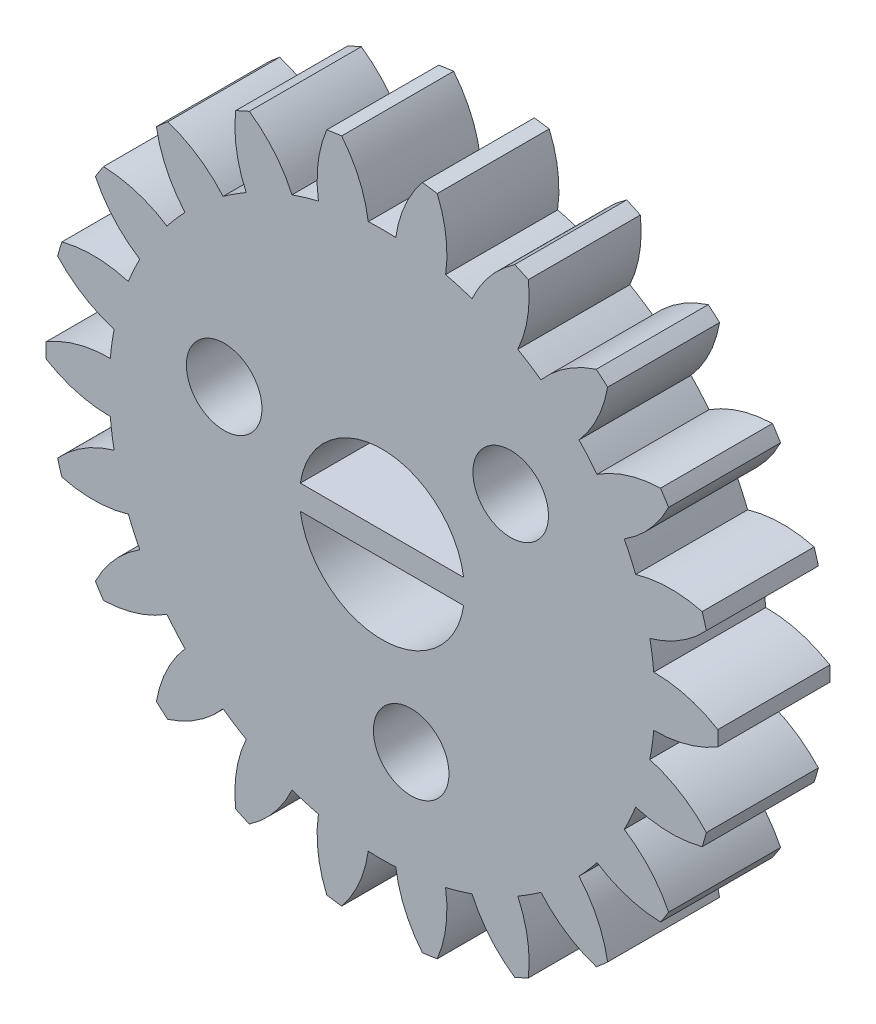
from build123d import *

# Parameters (mm, degrees)
MODEL_R             = 2.5
BOSS_EXTRUDE1_DEPTH = 4
SKETCH2_R           = 2.95
CUT_EXTRUDE1_DEPTH  = 4
SKETCH3_R           = 1.35
CUT_EXTRUDE2_DEPTH  = 4
CIRPATTERN1_COUNT   = 3
SKETCH5_W           = 6
SKETCH5_H           = 0.87
BOSS_EXTRUDE2_DEPTH = 4


with BuildPart() as part:
    # Model → Boss-Extrude1 (new body)
    with BuildSketch(Plane.XY):
        with BuildLine():
            ThreePointArc((-11.997000624, 0.268283487), (-12, 0), (-11.997000624, -0.268283487))
            ThreePointArc((-11.997000624, -0.268283487), (-10.895606779, -0.741380557), (-9.707399683, -0.89966238))
            ThreePointArc((-9.707399683, -0.89966238), (-9.649769237, -1.387427358), (-9.56764597, -1.8716708))
            ThreePointArc((-9.56764597, -1.8716708), (-10.663129188, -2.358297721), (-11.586621996, -3.122529539))
            ThreePointArc((-11.586621996, -3.122529539), (-11.513915683, -3.380790682), (-11.43545361, -3.637361781))
            ThreePointArc((-11.43545361, -3.637361781), (-10.245387108, -3.780996591), (-9.060717605, -3.598110265))
            ThreePointArc((-9.060717605, -3.598110265), (-8.868002323, -4.049880962), (-8.652778483, -4.491372344))
            ThreePointArc((-8.652778483, -4.491372344), (-9.566788286, -5.266920743), (-10.237564162, -6.260373793))
            ThreePointArc((-10.237564162, -6.260373793), (-10.095042394, -6.487689809), (-9.947474154, -6.711762656))
            ThreePointArc((-9.947474154, -6.711762656), (-8.765147105, -6.514298768), (-7.679990073, -6.005060656))
            ThreePointArc((-7.679990073, -6.005060656), (-7.3678026, -6.384237295), (-7.036914342, -6.747209612))
            ThreePointArc((-7.036914342, -6.747209612), (-7.695403093, -7.74884917), (-8.059119765, -8.891039794))
            ThreePointArc((-8.059119765, -8.891039794), (-7.858328807, -9.068994892), (-7.653609502, -9.242416436))
            ThreePointArc((-7.653609502, -9.242416436), (-6.574807012, -8.719851201), (-5.67707542, -7.925516745))
            ThreePointArc((-5.67707542, -7.925516745), (-5.270707329, -8.201380692), (-4.850961252, -8.456428084))
            ThreePointArc((-4.850961252, -8.456428084), (-5.200582107, -9.603011921), (-5.227773414, -10.801406627))
            ThreePointArc((-5.227773414, -10.801406627), (-4.984980156, -10.915583944), (-4.739694926, -11.024304604))
            ThreePointArc((-4.739694926, -11.024304604), (-3.851815156, -10.218973149), (-3.214237879, -9.203894603))
            ThreePointArc((-3.214237879, -9.203894603), (-2.746610697, -9.354097), (-2.27201213, -9.480557045))
            ThreePointArc((-2.27201213, -9.480557045), (-2.284440889, -10.679195758), (-1.972903952, -11.836707735))
            ThreePointArc((-1.972903952, -11.836707735), (-1.707778059, -11.877857303), (-1.441798455, -11.913069177))
            ThreePointArc((-1.441798455, -11.913069177), (-0.816772145, -10.890214666), (-0.491001901, -9.736627657))
            ThreePointArc((-0.491001901, -9.736627657), (0, -9.749), (0.491001901, -9.736627657))
            ThreePointArc((0.491001901, -9.736627657), (0.816772145, -10.890214666), (1.441798455, -11.913069177))
            ThreePointArc((1.441798455, -11.913069177), (1.707778059, -11.877857303), (1.972903952, -11.836707735))
            ThreePointArc((1.972903952, -11.836707735), (2.284440889, -10.679195758), (2.27201213, -9.480557045))
            ThreePointArc((2.27201213, -9.480557045), (2.746610697, -9.354097), (3.214237879, -9.203894603))
            ThreePointArc((3.214237879, -9.203894603), (3.851815156, -10.218973149), (4.739694926, -11.024304604))
            ThreePointArc((4.739694926, -11.024304604), (4.984980156, -10.915583944), (5.227773414, -10.801406627))
            ThreePointArc((5.227773414, -10.801406627), (5.200582107, -9.603011921), (4.850961252, -8.456428084))
            ThreePointArc((4.850961252, -8.456428084), (5.270707329, -8.201380692), (5.67707542, -7.925516745))
            ThreePointArc((5.67707542, -7.925516745), (6.574807012, -8.719851201), (7.653609502, -9.242416436))
            ThreePointArc((7.653609502, -9.242416436), (7.858328807, -9.068994892), (8.059119765, -8.891039794))
            ThreePointArc((8.059119765, -8.891039794), (7.695403093, -7.74884917), (7.036914342, -6.747209612))
            ThreePointArc((7.036914342, -6.747209612), (7.3678026, -6.384237295), (7.679990073, -6.005060656))
            ThreePointArc((7.679990073, -6.005060656), (8.765147105, -6.514298768), (9.947474154, -6.711762656))
            ThreePointArc((9.947474154, -6.711762656), (10.095042394, -6.487689809), (10.237564162, -6.260373793))
            ThreePointArc((10.237564162, -6.260373793), (9.566788286, -5.266920743), (8.652778482, -4.491372344))
            ThreePointArc((8.652778482, -4.491372344), (8.868002323, -4.049880962), (9.060717605, -3.598110265))
            ThreePointArc((9.060717605, -3.598110265), (10.245387108, -3.780996591), (11.43545361, -3.637361781))
            ThreePointArc((11.43545361, -3.637361781), (11.513915683, -3.380790682), (11.586621996, -3.122529539))
            ThreePointArc((11.586621996, -3.122529539), (10.663129188, -2.358297721), (9.56764597, -1.8716708))
            ThreePointArc((9.56764597, -1.8716708), (9.649769237, -1.387427358), (9.707399683, -0.89966238))
            ThreePointArc((9.707399683, -0.89966238), (10.895606779, -0.741380557), (11.997000624, -0.268283487))
            ThreePointArc((11.997000624, -0.268283487), (12, 0), (11.997000624, 0.268283487))
            ThreePointArc((11.997000624, 0.268283487), (10.895606779, 0.741380557), (9.707399683, 0.89966238))
            ThreePointArc((9.707399683, 0.89966238), (9.649769237, 1.387427358), (9.56764597, 1.8716708))
            ThreePointArc((9.56764597, 1.8716708), (10.663129188, 2.358297721), (11.586621996, 3.122529539))
            ThreePointArc((11.586621996, 3.122529539), (11.513915683, 3.380790682), (11.43545361, 3.637361781))
            ThreePointArc((11.43545361, 3.637361781), (10.245387108, 3.780996591), (9.060717605, 3.598110265))
            ThreePointArc((9.060717605, 3.598110265), (8.868002323, 4.049880962), (8.652778483, 4.491372344))
            ThreePointArc((8.652778483, 4.491372344), (9.566788286, 5.266920743), (10.237564162, 6.260373793))
            ThreePointArc((10.237564162, 6.260373793), (10.095042394, 6.487689809), (9.947474154, 6.711762656))
            ThreePointArc((9.947474154, 6.711762656), (8.765147105, 6.514298768), (7.679990073, 6.005060656))
            ThreePointArc((7.679990073, 6.005060656), (7.3678026, 6.384237295), (7.036914342, 6.747209612))
            ThreePointArc((7.036914342, 6.747209612), (7.695403093, 7.74884917), (8.059119765, 8.891039794))
            ThreePointArc((8.059119765, 8.891039794), (7.858328807, 9.068994892), (7.653609502, 9.242416436))
            ThreePointArc((7.653609502, 9.242416436), (6.574807012, 8.719851201), (5.67707542, 7.925516745))
            ThreePointArc((5.67707542, 7.925516745), (5.270707329, 8.201380692), (4.850961252, 8.456428084))
            ThreePointArc((4.850961252, 8.456428084), (5.200582107, 9.603011921), (5.227773414, 10.801406627))
            ThreePointArc((5.227773414, 10.801406627), (4.984980156, 10.915583944), (4.739694926, 11.024304604))
            ThreePointArc((4.739694926, 11.024304604), (3.851815156, 10.218973149), (3.214237879, 9.203894603))
            ThreePointArc((3.214237879, 9.203894603), (2.746610697, 9.354097), (2.27201213, 9.480557045))
            ThreePointArc((2.27201213, 9.480557045), (2.284440889, 10.679195758), (1.972903952, 11.836707735))
            ThreePointArc((1.972903952, 11.836707735), (1.707778059, 11.877857303), (1.441798455, 11.913069177))
            ThreePointArc((1.441798455, 11.913069177), (0.816772145, 10.890214666), (0.491001901, 9.736627657))
            ThreePointArc((0.491001901, 9.736627657), (0, 9.749), (-0.491001901, 9.736627657))
            ThreePointArc((-0.491001901, 9.736627657), (-0.816772145, 10.890214666), (-1.441798455, 11.913069177))
            ThreePointArc((-1.441798455, 11.913069177), (-1.707778059, 11.877857303), (-1.972903952, 11.836707735))
            ThreePointArc((-1.972903952, 11.836707735), (-2.284440889, 10.679195758), (-2.27201213, 9.480557045))
            ThreePointArc((-2.27201213, 9.480557045), (-2.746610697, 9.354097), (-3.214237879, 9.203894603))
            ThreePointArc((-3.214237879, 9.203894603), (-3.851815156, 10.218973149), (-4.739694926, 11.024304604))
            ThreePointArc((-4.739694926, 11.024304604), (-4.984980156, 10.915583944), (-5.227773414, 10.801406627))
            ThreePointArc((-5.227773414, 10.801406627), (-5.200582107, 9.603011921), (-4.850961252, 8.456428084))
            ThreePointArc((-4.850961252, 8.456428084), (-5.270707329, 8.201380692), (-5.67707542, 7.925516745))
            ThreePointArc((-5.67707542, 7.925516745), (-6.574807012, 8.719851201), (-7.653609502, 9.242416436))
            ThreePointArc((-7.653609502, 9.242416436), (-7.858328807, 9.068994892), (-8.059119765, 8.891039794))
            ThreePointArc((-8.059119765, 8.891039794), (-7.695403093, 7.74884917), (-7.036914342, 6.747209612))
            ThreePointArc((-7.036914342, 6.747209612), (-7.3678026, 6.384237295), (-7.679990073, 6.005060656))
            ThreePointArc((-7.679990073, 6.005060656), (-8.765147105, 6.514298768), (-9.947474154, 6.711762656))
            ThreePointArc((-9.947474154, 6.711762656), (-10.095042394, 6.487689809), (-10.237564162, 6.260373793))
            ThreePointArc((-10.237564162, 6.260373793), (-9.566788286, 5.266920743), (-8.652778482, 4.491372344))
            ThreePointArc((-8.652778482, 4.491372344), (-8.868002323, 4.049880962), (-9.060717605, 3.598110265))
            ThreePointArc((-9.060717605, 3.598110265), (-10.245387108, 3.780996591), (-11.43545361, 3.637361781))
            ThreePointArc((-11.43545361, 3.637361781), (-11.513915683, 3.380790682), (-11.586621996, 3.122529539))
            ThreePointArc((-11.586621996, 3.122529539), (-10.663129188, 2.358297721), (-9.56764597, 1.8716708))
            ThreePointArc((-9.56764597, 1.8716708), (-9.649769237, 1.387427358), (-9.707399683, 0.89966238))
            ThreePointArc((-9.707399683, 0.89966238), (-10.895606779, 0.741380557), (-11.997000624, 0.268283487))
        make_face()
        Circle(MODEL_R, mode=Mode.SUBTRACT)
    extrude(amount=BOSS_EXTRUDE1_DEPTH)

    # Sketch2 → Cut-Extrude1 (cut)
    with BuildSketch(Plane.XY.offset(4)):
        Circle(SKETCH2_R)
    extrude(amount=-CUT_EXTRUDE1_DEPTH, mode=Mode.SUBTRACT)

    # Sketch3 → Cut-Extrude2 (cut)
    with BuildSketch(Plane.XY.offset(4)):
        with Locations((-5.638155725, 2.05212086)):
            Circle(SKETCH3_R)
    cut_extrude2 = extrude(amount=-CUT_EXTRUDE2_DEPTH, mode=Mode.SUBTRACT)

    # CirPattern1: Cut-Extrude2 ×3 about axis
    cirpattern1_axis = Axis((0, 0, 0), (0, 0, 1))
    for i in range(1, CIRPATTERN1_COUNT):
        add(cut_extrude2.rotate(cirpattern1_axis, i * 360 / CIRPATTERN1_COUNT), mode=Mode.SUBTRACT)

    # Sketch5 → Boss-Extrude2 (add)
    with BuildSketch(Plane.XY):
        Rectangle(SKETCH5_W, SKETCH5_H)
    extrude(amount=BOSS_EXTRUDE2_DEPTH)


solid = part.part
